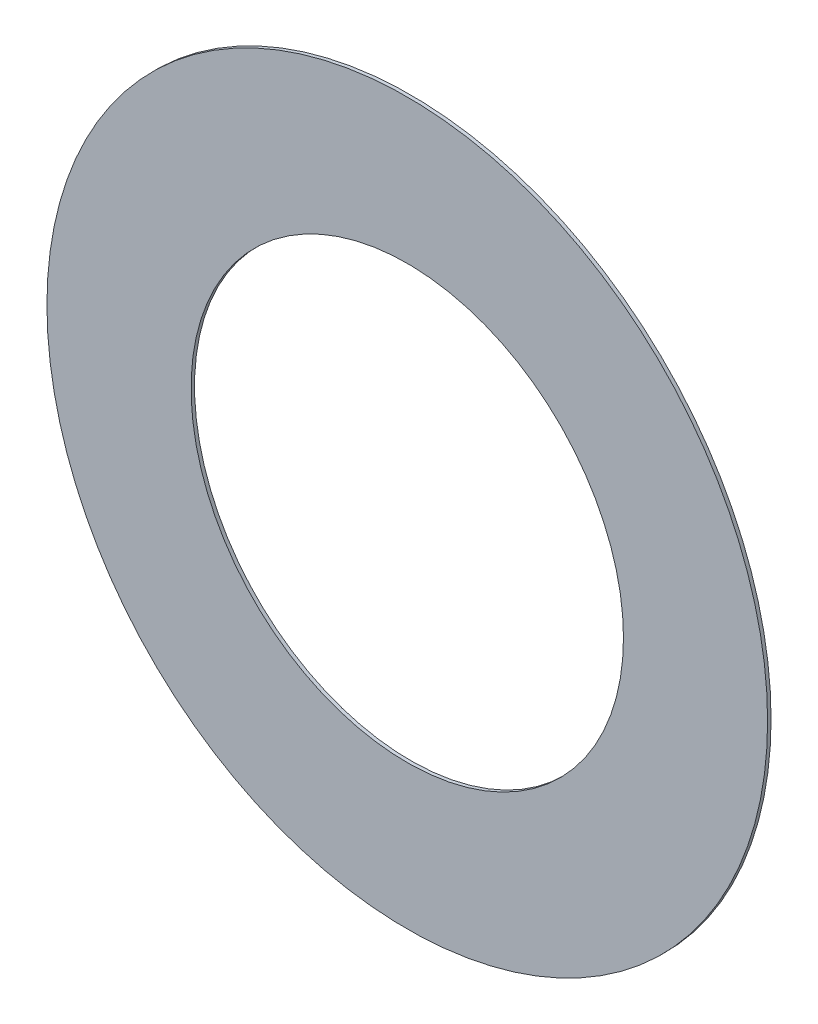
from build123d import *

# Parameters (mm, degrees)
SKETCH1_R           = 7.9375
SKETCH1_R_2         = 4.7625
BOSS_EXTRUDE1_DEPTH = 0.0762


with BuildPart() as part:
    # Sketch1 → Boss-Extrude1 (new body)
    with BuildSketch(Plane.XY):
        Circle(SKETCH1_R)
        Circle(SKETCH1_R_2, mode=Mode.SUBTRACT)
    extrude(amount=BOSS_EXTRUDE1_DEPTH)


solid = part.part
